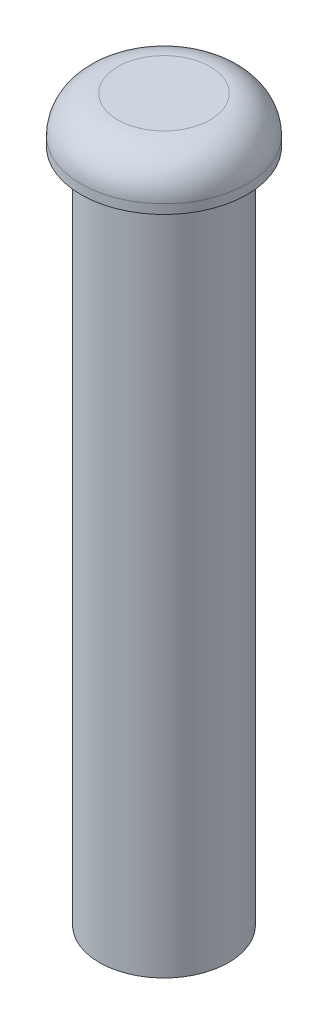
from build123d import *

# Parameters (mm, degrees)
SKETCH1_R           = 7
BOSS_EXTRUDE1_DEPTH = 73
SKETCH2_R           = 9
BOSS_EXTRUDE2_DEPTH = 5
FILLET3_R           = 4


with BuildPart() as part:
    # Sketch1 → Boss-Extrude1 (new body)
    with BuildSketch(Plane(origin=(0, 0, 0), x_dir=(1, 0, 0), z_dir=(0, 1, 0))):
        Circle(SKETCH1_R)
    extrude(amount=BOSS_EXTRUDE1_DEPTH)

    # Sketch2 → Boss-Extrude2 (add)
    with BuildSketch(Plane(origin=(0, 73, 0), x_dir=(1, 0, 0), z_dir=(0, 1, 0))):
        Circle(SKETCH2_R)
    extrude(amount=BOSS_EXTRUDE2_DEPTH)

    # Fillet3
    fillet3_edges = [part.edges().sort_by_distance(p)[0] for p in [
        (-9, 78, 0),
    ]]
    fillet(fillet3_edges, radius=FILLET3_R)


solid = part.part
